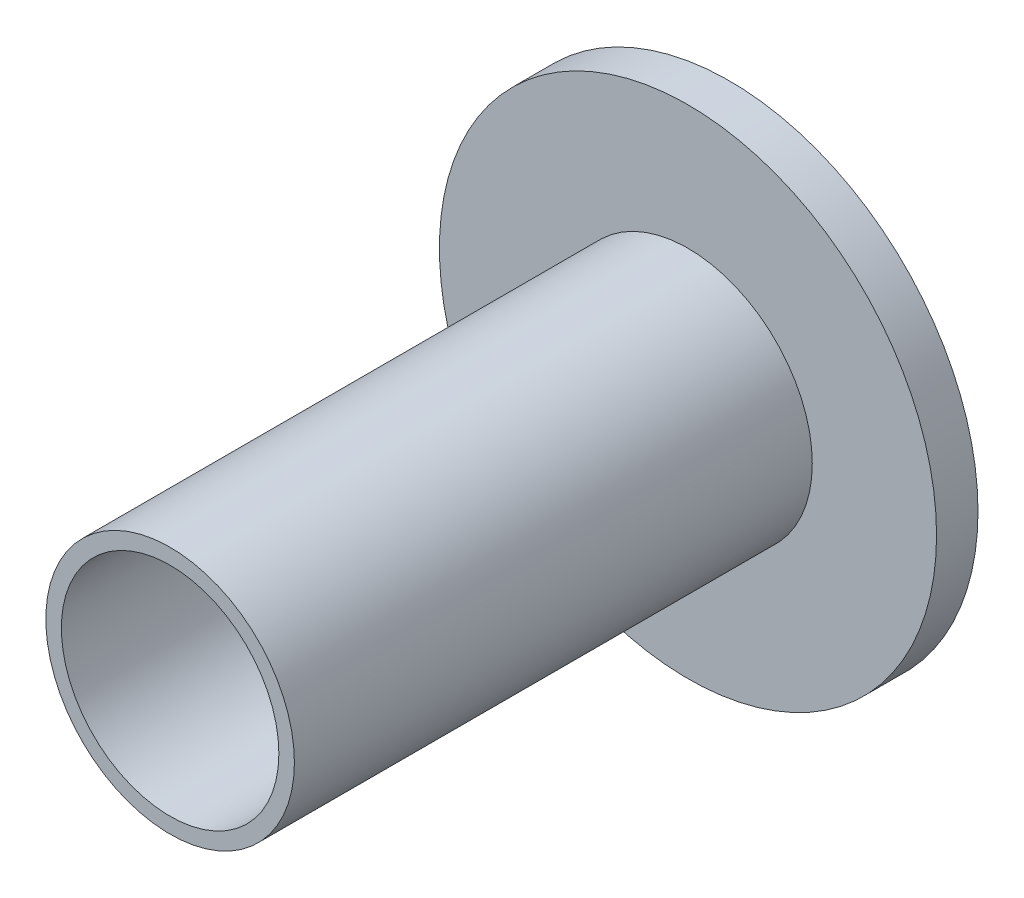
from build123d import *

# Parameters (mm, degrees)
IZIM1_R                     = 12
Y_KSEKLIK_EKSTR_ZYON1_DEPTH = 2
IZIM2_R                     = 6
Y_KSEKLIK_EKSTR_ZYON2_DEPTH = 25
IZIM3_R                     = 5.25
KES_EKSTR_ZYON1_DEPTH       = 37


with BuildPart() as part:
    # Çizim1 → Yükseklik-Ekstrüzyon1 (new body)
    with BuildSketch(Plane.XY):
        Circle(IZIM1_R)
    extrude(amount=Y_KSEKLIK_EKSTR_ZYON1_DEPTH)

    # Çizim2 → Yükseklik-Ekstrüzyon2 (add)
    with BuildSketch(Plane.XY.offset(2)):
        Circle(IZIM2_R)
    extrude(amount=Y_KSEKLIK_EKSTR_ZYON2_DEPTH)

    # Çizim3 → Kes-Ekstrüzyon1 (cut)
    with BuildSketch(Plane.XY.offset(27)):
        Circle(IZIM3_R)
    extrude(amount=-KES_EKSTR_ZYON1_DEPTH, mode=Mode.SUBTRACT)


solid = part.part
